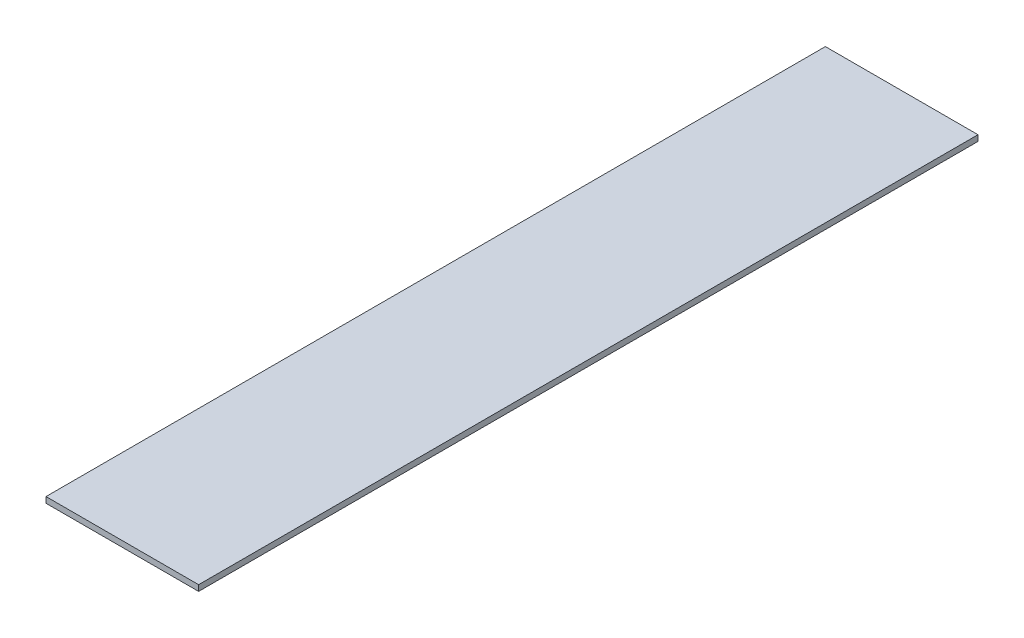
from build123d import *

# Parameters (mm, degrees)
SKETCH1_W           = 470
SKETCH1_H           = 2400
BOSS_EXTRUDE1_DEPTH = 18


with BuildPart() as part:
    # Sketch1 → Boss-Extrude1 (new body)
    with BuildSketch(Plane(origin=(0, 0, 0), x_dir=(1, 0, 0), z_dir=(0, 1, 0))):
        with Locations((235, 1200)):
            Rectangle(SKETCH1_W, SKETCH1_H)
    extrude(amount=BOSS_EXTRUDE1_DEPTH)


solid = part.part
